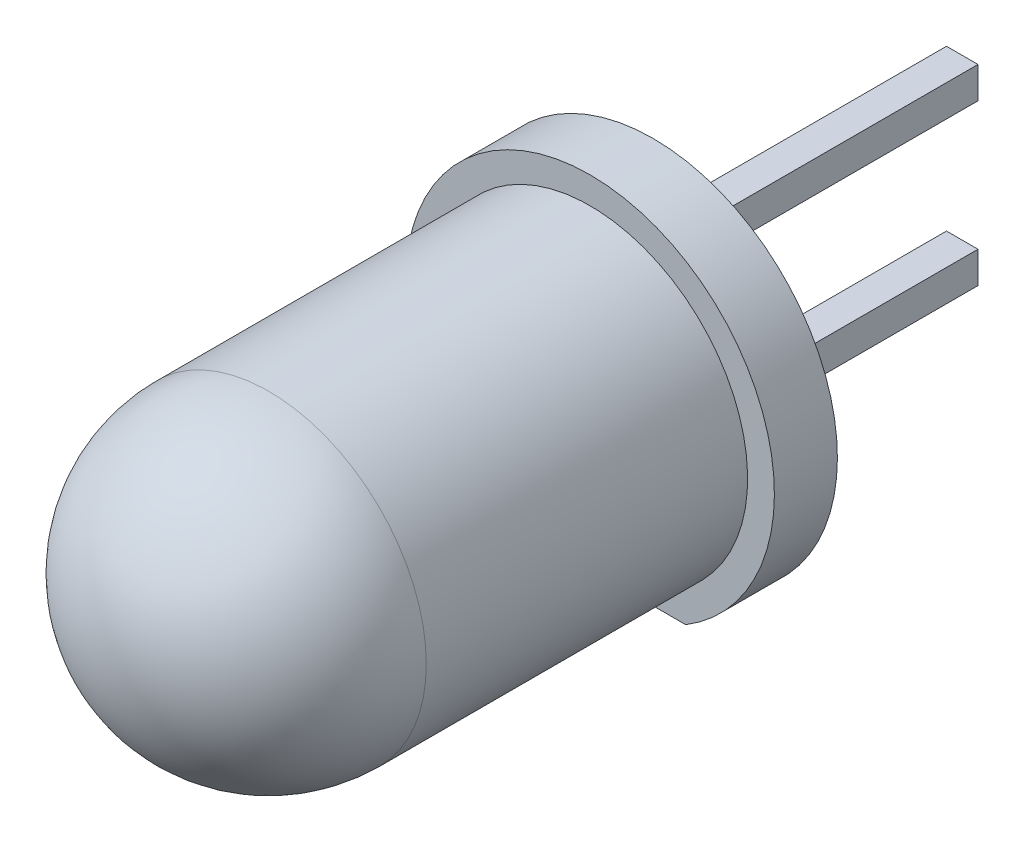
from build123d import *

# Parameters (mm, degrees)
SKETCH1_R           = 2.5
SKETCH1_R_2         = 2
BOSS_EXTRUDE1_DEPTH = 5.1
REVOLVE1_ANGLE      = 180
SKETCH5_R           = 2.925
BOSS_EXTRUDE2_DEPTH = 1
BOSS_EXTRUDE3_DEPTH = 0.25
SKETCH13_W          = 0.5
SKETCH13_H          = 0.5
BOSS_EXTRUDE4_DEPTH = 5
CUT_EXTRUDE2_DEPTH  = 5


with BuildPart() as part:
    # Sketch1 → Boss-Extrude1 (new body)
    with BuildSketch(Plane.XY):
        Circle(SKETCH1_R)
        Circle(SKETCH1_R_2, mode=Mode.SUBTRACT)
    extrude(amount=BOSS_EXTRUDE1_DEPTH)

    # Sketch4 → Revolve1 (revolve)
    with BuildSketch(Plane.XY.offset(5.1)):
        with BuildLine():
            Line((-2, 0), (-2.5, 0))
            ThreePointArc((-2.5, 0), (0, 2.5), (2.5, 0))
            Line((2.5, 0), (2, 0))
            ThreePointArc((2, 0), (0, 2), (-2, 0))
        make_face()
    revolve(axis=Axis((-2.5, 0, 5.1), (1, 0, 0)), revolution_arc=REVOLVE1_ANGLE)

    # Sketch5 → Boss-Extrude2 (add)
    with BuildSketch(Plane(origin=(0, 0, 0), x_dir=(-1, 0, 0), z_dir=(0, 0, -1))):
        Circle(SKETCH5_R)
    extrude(amount=BOSS_EXTRUDE2_DEPTH)

    # Sketch8 → Boss-Extrude3 (add, symmetric)
    with BuildSketch(Plane(origin=(0, 0, 0), x_dir=(0, 0, -1), z_dir=(1, 0, 0))):
        Polygon((0, 1.072701591), (-3.556166294, 1.072701591), (-3.556166294, -0.218813925), (-2.37503672, 0.509733289), (-2.37503672, 0.763620955), (0, 0.763620955), align=None)
        Polygon((-3.556166294, -0.41750862), (-3.330966178, -0.41750862), (-3.330966178, -0.31503842), (-2.37503672, 0.3), (-2.37503672, -0.41750862), (0, -0.41750862), (0, -0.914245357), (-3.556166294, -0.914245357), align=None)
    extrude(amount=BOSS_EXTRUDE3_DEPTH, both=True)

    # Sketch13 → Boss-Extrude4 (add)
    with BuildSketch(Plane(origin=(0, 0, -1), x_dir=(-1, 0, 0), z_dir=(0, 0, -1))):
        with Locations((0.093693205, -1.27)):
            Rectangle(SKETCH13_W, SKETCH13_H)
        with Locations((0.093693205, 1.27)):
            Rectangle(SKETCH13_W, SKETCH13_H)
    extrude(amount=BOSS_EXTRUDE4_DEPTH)

    # Sketch14 → Cut-Extrude2 (cut)
    with BuildSketch(Plane.XY):
        with BuildLine():
            Line((1.518428464, -2.5), (-1.518428464, -2.5))
            ThreePointArc((-1.518428464, -2.5), (0, -2.925), (1.518428464, -2.5))
        make_face()
    extrude(amount=-CUT_EXTRUDE2_DEPTH, mode=Mode.SUBTRACT)


solid = part.part
